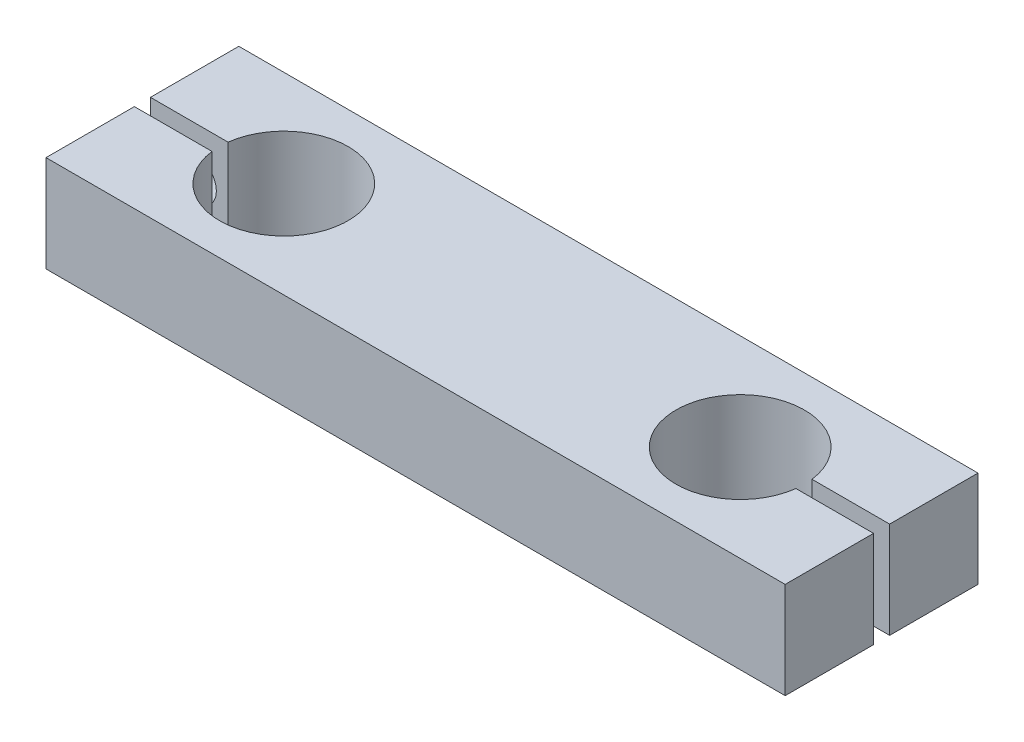
from build123d import *

# Parameters (mm, degrees)
BOSS_EXTRUDE1_DEPTH = 15
SKETCH2_R           = 5.25
CUT_EXTRUDE1_DEPTH  = 7
SKETCH3_R           = 3.25
CUT_EXTRUDE2_DEPTH  = 20


with BuildPart() as part:
    # Sketch1 → Boss-Extrude1 (new body)
    with BuildSketch(Plane(origin=(0, 0, 0), x_dir=(1, 0, 0), z_dir=(0, 1, 0))):
        with BuildLine():
            Line((57.5, 15), (-57.5, 15))
            Line((-57.5, 15), (-57.5, 1.25))
            Line((-57.5, 1.25), (-45.421567416, 1.25))
            ThreePointArc((-45.421567416, 1.25), (-34.873770875, 9.980372592), (-25.5, 0))
            ThreePointArc((-25.5, 0), (-34.873770875, -9.980372592), (-45.421567416, -1.25))
            Line((-45.421567416, -1.25), (-57.5, -1.25))
            Line((-57.5, -1.25), (-57.5, -15))
            Line((-57.5, -15), (57.5, -15))
            Line((57.5, -15), (57.5, -1.25))
            Line((57.5, -1.25), (45.421567416, -1.25))
            ThreePointArc((45.421567416, -1.25), (25.5, 0), (45.421567416, 1.25))
            Line((45.421567416, 1.25), (57.5, 1.25))
            Line((57.5, 1.25), (57.5, 15))
        make_face()
    extrude(amount=BOSS_EXTRUDE1_DEPTH)

    # Sketch2 → Cut-Extrude1 (cut)
    with BuildSketch(Plane(origin=(0, 0, -15), x_dir=(-1, 0, 0), z_dir=(0, 0, -1))):
        with Locations((-50.5, 7.5)):
            Circle(SKETCH2_R)
        with Locations((50.5, 7.5)):
            Circle(SKETCH2_R)
    extrude(amount=-CUT_EXTRUDE1_DEPTH, mode=Mode.SUBTRACT)

    # Sketch3 → Cut-Extrude2 (cut)
    with BuildSketch(Plane(origin=(0, 0, -8), x_dir=(-1, 0, 0), z_dir=(0, 0, -1))):
        with Locations((-50.5, 7.5)):
            Circle(SKETCH3_R)
        with Locations((50.5, 7.5)):
            Circle(SKETCH3_R)
    extrude(amount=-CUT_EXTRUDE2_DEPTH, mode=Mode.SUBTRACT)


solid = part.part
